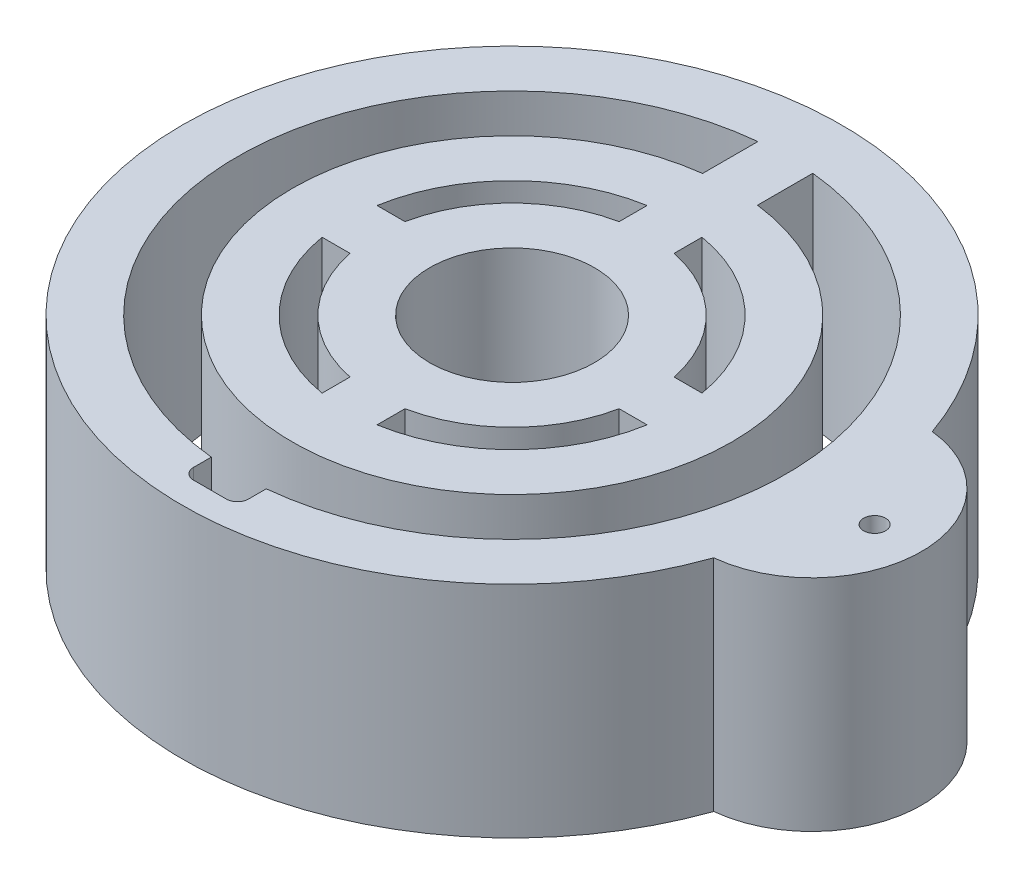
from build123d import *

# Parameters (mm, degrees)
SKETCH1_R           = 30
SKETCH1_R_2         = 15
BOSS_EXTRUDE1_DEPTH = 20
BOSS_EXTRUDE2_DEPTH = 20
SKETCH3_R           = 1
CUT_EXTRUDE1_DEPTH  = 20
SKETCH4_R           = 7.5
BOSS_EXTRUDE3_DEPTH = 20


with BuildPart() as part:
    # Sketch1 → Boss-Extrude1 (new body)
    with BuildSketch(Plane(origin=(0, 0, 0), x_dir=(1, 0, 0), z_dir=(0, 1, 0))):
        Circle(SKETCH1_R)
        with BuildLine():
            ThreePointArc((-2.5, -24.874685928), (-25, 0), (-2.5, 24.874685928))
            Line((-2.5, 24.874685928), (-2.5, 19.843134833))
            ThreePointArc((-2.5, 19.843134833), (0, -20), (2.5, 19.843134833))
            Line((2.5, 19.843134833), (2.5, 24.874685928))
            ThreePointArc((2.5, 24.874685928), (25, 0), (2.5, -24.874685928))
            Line((2.5, -24.874685928), (2.5, -26.5))
            ThreePointArc((2.5, -26.5), (2.207106781, -27.207106781), (1.5, -27.5))
            Line((1.5, -27.5), (-1.5, -27.5))
            ThreePointArc((-1.5, -27.5), (-2.207106781, -27.207106781), (-2.5, -26.5))
            Line((-2.5, -26.5), (-2.5, -24.874685928))
        make_face(mode=Mode.SUBTRACT)
        Circle(SKETCH1_R_2, mode=Mode.SUBTRACT)
    extrude(amount=BOSS_EXTRUDE1_DEPTH)

    # Sketch2 → Boss-Extrude2 (add)
    with BuildSketch(Plane(origin=(0, 20, 0), x_dir=(1, 0, 0), z_dir=(0, 1, 0))):
        with BuildLine():
            Line((27.271780287, 10), (27.271780287, -10))
            ThreePointArc((27.271780287, -10), (37.271780287, 0), (27.271780287, 10))
        make_face()
    extrude(amount=-BOSS_EXTRUDE2_DEPTH)

    # Sketch3 → Cut-Extrude1 (cut)
    with BuildSketch(Plane(origin=(0, 20, 0), x_dir=(1, 0, 0), z_dir=(0, 1, 0))):
        with Locations((33, 0)):
            Circle(SKETCH3_R)
    extrude(amount=-CUT_EXTRUDE1_DEPTH, mode=Mode.SUBTRACT)

    # Sketch4 → Boss-Extrude3 (add)
    with BuildSketch(Plane(origin=(0, 0, 0), x_dir=(1, 0, 0), z_dir=(0, 1, 0))):
        with BuildLine():
            Line((-2.5, 19.843134833), (2.5, 19.843134833))
            Line((2.5, 19.843134833), (2.5, 12.247448714))
            ThreePointArc((2.5, 12.247448714), (8.838834765, 8.838834765), (12.247448714, 2.5))
            Line((12.247448714, 2.5), (16.124945742, 2.5))
            Line((16.124945742, 2.5), (16.124945742, -2.5))
            Line((16.124945742, -2.5), (12.247448714, -2.5))
            ThreePointArc((12.247448714, -2.5), (8.838834765, -8.838834765), (2.5, -12.247448714))
            Line((2.5, -12.247448714), (2.5, -17.575657714))
            Line((2.5, -17.575657714), (-2.5, -17.575657714))
            Line((-2.5, -17.575657714), (-2.5, -12.247448714))
            ThreePointArc((-2.5, -12.247448714), (-8.838834765, -8.838834765), (-12.247448714, -2.5))
            Line((-12.247448714, -2.5), (-16.958645249, -2.5))
            Line((-16.958645249, -2.5), (-16.958645249, 2.5))
            Line((-16.958645249, 2.5), (-12.247448714, 2.5))
            ThreePointArc((-12.247448714, 2.5), (-8.838834765, 8.838834765), (-2.5, 12.247448714))
            Line((-2.5, 12.247448714), (-2.5, 19.843134833))
        make_face()
        Circle(SKETCH4_R, mode=Mode.SUBTRACT)
    extrude(amount=BOSS_EXTRUDE3_DEPTH)


solid = part.part
